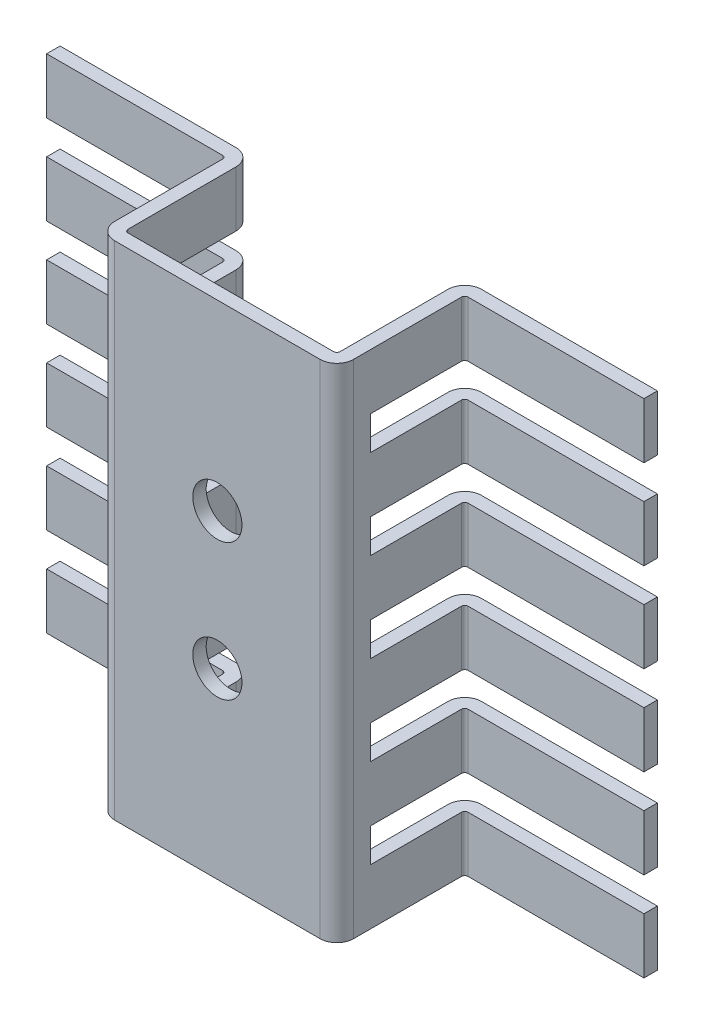
from build123d import *

# Parameters (mm, degrees)
EXTRUDE_THIN1_DEPTH = 37.34
SKETCH2_R           = 1.83
CUT_EXTRUDE1_DEPTH  = 11.52
SKETCH3_W           = 44.45
SKETCH3_H           = 2.5
CUT_EXTRUDE2_DEPTH  = 8


with BuildPart() as part:
    # Sketch1 → Extrude-Thin1 (new body)
    with BuildSketch(Plane(origin=(0, 0, 0), x_dir=(1, 0, 0), z_dir=(0, 1, 0))):
        with BuildLine():
            Line((-22.225, 9.52), (-9.14, 9.52))
            ThreePointArc((-9.14, 9.52), (-8.963223305, 9.446776695), (-8.89, 9.27))
            Line((-8.89, 9.27), (-8.89, 1.25))
            ThreePointArc((-8.89, 1.25), (-8.523883476, 0.366116524), (-7.64, 0))
            Line((-7.64, 0), (7.64, 0))
            ThreePointArc((7.64, 0), (8.523883476, 0.366116524), (8.89, 1.25))
            Line((8.89, 1.25), (8.89, 9.27))
            ThreePointArc((8.89, 9.27), (8.963223305, 9.446776695), (9.14, 9.52))
            Line((9.14, 9.52), (22.225, 9.52))
            Line((22.225, 9.52), (22.225, 10.52))
            Line((22.225, 10.52), (9.14, 10.52))
            ThreePointArc((9.14, 10.52), (8.256116524, 10.153883476), (7.89, 9.27))
            Line((7.89, 9.27), (7.89, 1.25))
            ThreePointArc((7.89, 1.25), (7.816776695, 1.073223305), (7.64, 1))
            Line((7.64, 1), (-7.64, 1))
            ThreePointArc((-7.64, 1), (-7.816776695, 1.073223305), (-7.89, 1.25))
            Line((-7.89, 1.25), (-7.89, 9.27))
            ThreePointArc((-7.89, 9.27), (-8.256116524, 10.153883476), (-9.14, 10.52))
            Line((-9.14, 10.52), (-22.225, 10.52))
            Line((-22.225, 10.52), (-22.225, 9.52))
        make_face()
    extrude(amount=EXTRUDE_THIN1_DEPTH)

    # Sketch2 → Cut-Extrude1 (cut, through all)
    with BuildSketch(Plane.XY):
        with Locations((0, 13.59)):
            Circle(SKETCH2_R)
        with Locations((0, 23.75)):
            Circle(SKETCH2_R)
    extrude(amount=-CUT_EXTRUDE1_DEPTH, mode=Mode.SUBTRACT)

    # Sketch3 → Cut-Extrude2 (cut)
    with BuildSketch(Plane(origin=(0, 0, -10.52), x_dir=(-1, 0, 0), z_dir=(0, 0, -1))):
        with Locations((0, 31.95)):
            Rectangle(SKETCH3_W, SKETCH3_H)
        with Locations((0, 25.31)):
            Rectangle(SKETCH3_W, SKETCH3_H)
        with Locations((0, 18.67)):
            Rectangle(SKETCH3_W, SKETCH3_H)
        with Locations((0, 12.03)):
            Rectangle(SKETCH3_W, SKETCH3_H)
        with Locations((0, 5.39)):
            Rectangle(SKETCH3_W, SKETCH3_H)
    extrude(amount=-CUT_EXTRUDE2_DEPTH, mode=Mode.SUBTRACT)


solid = part.part
